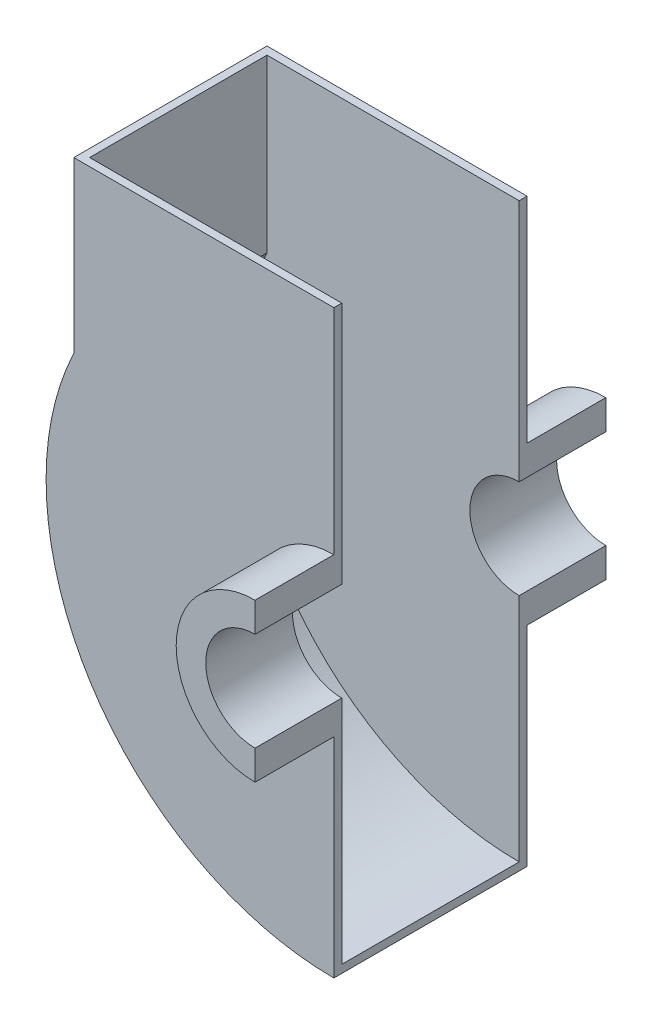
from build123d import *

# Parameters (mm, degrees)
BOSS_EXTRUDE1_DEPTH = 24.5
SHELL1_T            = -2
BOSS_EXTRUDE2_DEPTH = 20


with BuildPart() as part:
    # Sketch1 → Boss-Extrude1 (new body, symmetric)
    with BuildSketch(Plane.XY):
        with BuildLine():
            Line((0, 0), (65.97, 0))
            Line((65.97, 0), (65.97, -61.756344956))
            ThreePointArc((65.97, -61.756344956), (53.47, -74.256344956), (65.97, -86.756344956))
            Line((65.97, -86.756344956), (65.97, -147.256344956))
            ThreePointArc((65.97, -147.256344956), (4.282427581, -113.290220104), (0, -43))
            Line((0, -43), (0, 0))
        make_face()
    extrude(amount=BOSS_EXTRUDE1_DEPTH, both=True)

    # Shell1
    shell1_openings = [part.faces().sort_by_distance(p)[0] for p in [
        (32.985, 0, 0),
        (65.97, -30.878172478, 0),
        (59.72, -74.256344956, 0),
        (65.97, -117.006344956, 0),
    ]]
    offset(amount=SHELL1_T, openings=shell1_openings, kind=Kind.INTERSECTION)

    # Sketch2 → Boss-Extrude2 (add)
    with BuildSketch(Plane.XY.offset(24.5)):
        with BuildLine():
            Line((65.97, -54.256344956), (65.97, -61.756344956))
            ThreePointArc((65.97, -61.756344956), (53.47, -74.256344956), (65.97, -86.756344956))
            Line((65.97, -86.756344956), (65.97, -94.256344956))
            ThreePointArc((65.97, -94.256344956), (45.97, -74.256344956), (65.97, -54.256344956))
        make_face()
    boss_extrude2 = extrude(amount=BOSS_EXTRUDE2_DEPTH)

    # Mirror1: Boss-Extrude2 across plane
    add(boss_extrude2.mirror(Plane.XY))


solid = part.part
